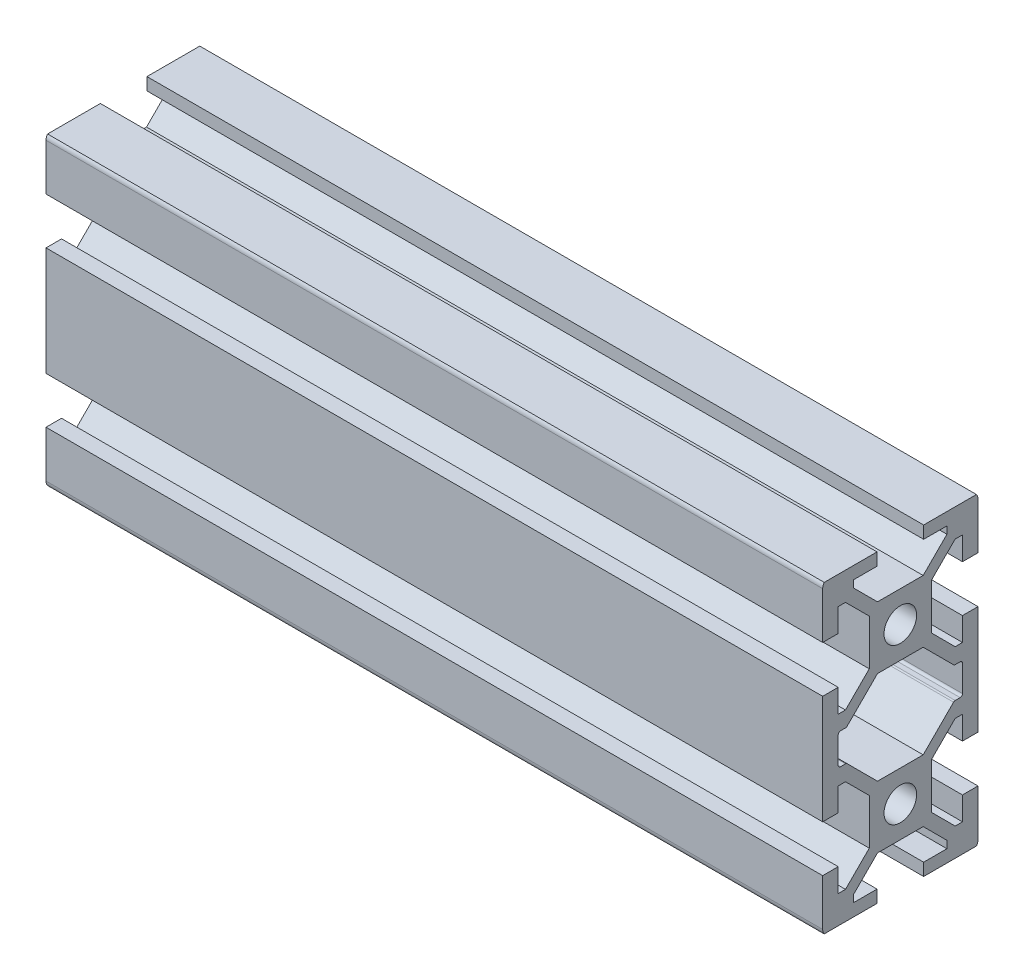
from build123d import *

# Parameters (mm, degrees)
SKETCH1_R           = 2.1
BOSS_EXTRUDE1_DEPTH = 100


with BuildPart() as part:
    # Sketch1 → Boss-Extrude1 (new body)
    with BuildSketch(Plane(origin=(0, 0, 0), x_dir=(0, 0, -1), z_dir=(1, 0, 0))):
        with BuildLine():
            Line((-10, 7), (-10, -7))
            Line((-10, -7), (-8, -7))
            Line((-8, -7), (-8, -4))
            Line((-8, -4), (-7.060660172, -4))
            Line((-7.060660172, -4), (-4, -7.060660172))
            Line((-4, -7.060660172), (-4, -12.939339828))
            Line((-4, -12.939339828), (-7.060660172, -16))
            Line((-7.060660172, -16), (-8, -16))
            Line((-8, -16), (-8, -13))
            Line((-8, -13), (-10, -13))
            Line((-10, -13), (-10, -19))
            ThreePointArc((-10, -19), (-9.948683298, -19.316227766), (-9.8, -19.6))
            Line((-9.8, -19.6), (-3, -19.6))
            Line((-3, -19.6), (-3, -18))
            Line((-3, -18), (-6, -18))
            Line((-6, -18), (-6, -17.060660172))
            Line((-6, -17.060660172), (-2.939339828, -14))
            Line((-2.939339828, -14), (2.939339828, -14))
            Line((2.939339828, -14), (6, -17.060660172))
            Line((6, -17.060660172), (6, -18))
            Line((6, -18), (3, -18))
            Line((3, -18), (3, -19.6))
            Line((3, -19.6), (9.8, -19.6))
            ThreePointArc((9.8, -19.6), (9.948683298, -19.316227766), (10, -19))
            Line((10, -19), (10, -13))
            Line((10, -13), (8, -13))
            Line((8, -13), (8, -16))
            Line((8, -16), (7.060660172, -16))
            Line((7.060660172, -16), (4, -12.939339828))
            Line((4, -12.939339828), (4, -7.060660172))
            Line((4, -7.060660172), (7.060660172, -4))
            Line((7.060660172, -4), (8, -4))
            Line((8, -4), (8, -7))
            Line((8, -7), (10, -7))
            Line((10, -7), (10, 7))
            Line((10, 7), (8, 7))
            Line((8, 7), (8, 4))
            Line((8, 4), (7.060660172, 4))
            Line((7.060660172, 4), (4, 7.060660172))
            Line((4, 7.060660172), (4, 12.939339828))
            Line((4, 12.939339828), (7.060660172, 16))
            Line((7.060660172, 16), (8, 16))
            Line((8, 16), (8, 13))
            Line((8, 13), (10, 13))
            Line((10, 13), (10, 19))
            ThreePointArc((10, 19), (9.948683298, 19.316227766), (9.8, 19.6))
            Line((9.8, 19.6), (3, 19.6))
            Line((3, 19.6), (3, 18))
            Line((3, 18), (6, 18))
            Line((6, 18), (6, 17.060660172))
            Line((6, 17.060660172), (2.939339828, 14))
            Line((2.939339828, 14), (-2.939339828, 14))
            Line((-2.939339828, 14), (-6, 17.060660172))
            Line((-6, 17.060660172), (-6, 18))
            Line((-6, 18), (-3, 18))
            Line((-3, 18), (-3, 19.6))
            Line((-3, 19.6), (-9.8, 19.6))
            ThreePointArc((-9.8, 19.6), (-9.948683298, 19.316227766), (-10, 19))
            Line((-10, 19), (-10, 13))
            Line((-10, 13), (-8, 13))
            Line((-8, 13), (-8, 16))
            Line((-8, 16), (-7.060660172, 16))
            Line((-7.060660172, 16), (-4, 12.939339828))
            Line((-4, 12.939339828), (-4, 7.060660172))
            Line((-4, 7.060660172), (-7.060660172, 4))
            Line((-7.060660172, 4), (-8, 4))
            Line((-8, 4), (-8, 7))
            Line((-8, 7), (-10, 7))
        make_face()
        with Locations((0, 10)):
            Circle(SKETCH1_R, mode=Mode.SUBTRACT)
        with Locations((0, -10)):
            Circle(SKETCH1_R, mode=Mode.SUBTRACT)
        with BuildLine():
            Line((-8, 1.7), (-8, -1.7))
            ThreePointArc((-8, -1.7), (-7.912132034, -1.912132034), (-7.7, -2))
            Line((-7.7, -2), (-7.063603897, -2))
            ThreePointArc((-7.063603897, -2), (-6.948798867, -2.02283614), (-6.851471863, -2.087867966))
            Line((-6.851471863, -2.087867966), (-2.939339828, -6))
            Line((-2.939339828, -6), (2.939339828, -6))
            Line((2.939339828, -6), (6.851471863, -2.087867966))
            ThreePointArc((6.851471863, -2.087867966), (6.948798867, -2.02283614), (7.063603897, -2))
            Line((7.063603897, -2), (7.7, -2))
            ThreePointArc((7.7, -2), (7.912132034, -1.912132034), (8, -1.7))
            Line((8, -1.7), (8, 1.7))
            ThreePointArc((8, 1.7), (7.912132034, 1.912132034), (7.7, 2))
            Line((7.7, 2), (7.063603897, 2))
            ThreePointArc((7.063603897, 2), (6.948798867, 2.02283614), (6.851471863, 2.087867966))
            Line((6.851471863, 2.087867966), (2.939339828, 6))
            Line((2.939339828, 6), (-2.939339828, 6))
            Line((-2.939339828, 6), (-6.851471863, 2.087867966))
            ThreePointArc((-6.851471863, 2.087867966), (-6.948798867, 2.02283614), (-7.063603897, 2))
            Line((-7.063603897, 2), (-7.7, 2))
            ThreePointArc((-7.7, 2), (-7.912132034, 1.912132034), (-8, 1.7))
        make_face(mode=Mode.SUBTRACT)
    extrude(amount=BOSS_EXTRUDE1_DEPTH)


solid = part.part
